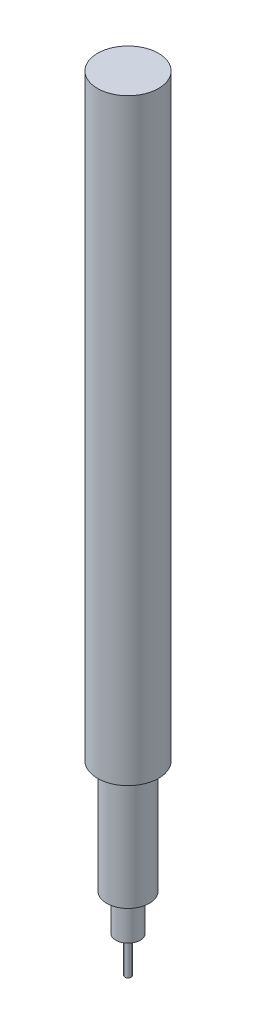
from build123d import *


with BuildPart() as part:
    # Esboço1 → Revolução1 (revolve)
    with BuildSketch(Plane.XY):
        Polygon((0, 0), (0.5, 0), (0.5, 5), (2, 6), (2, 12), (3.5, 12), (3.5, 30.5), (5, 30.5), (5, 128.5), (0, 128.5), align=None)
    revolve(axis=Axis((0, 0, 0), (0, 1, 0)))


solid = part.part
